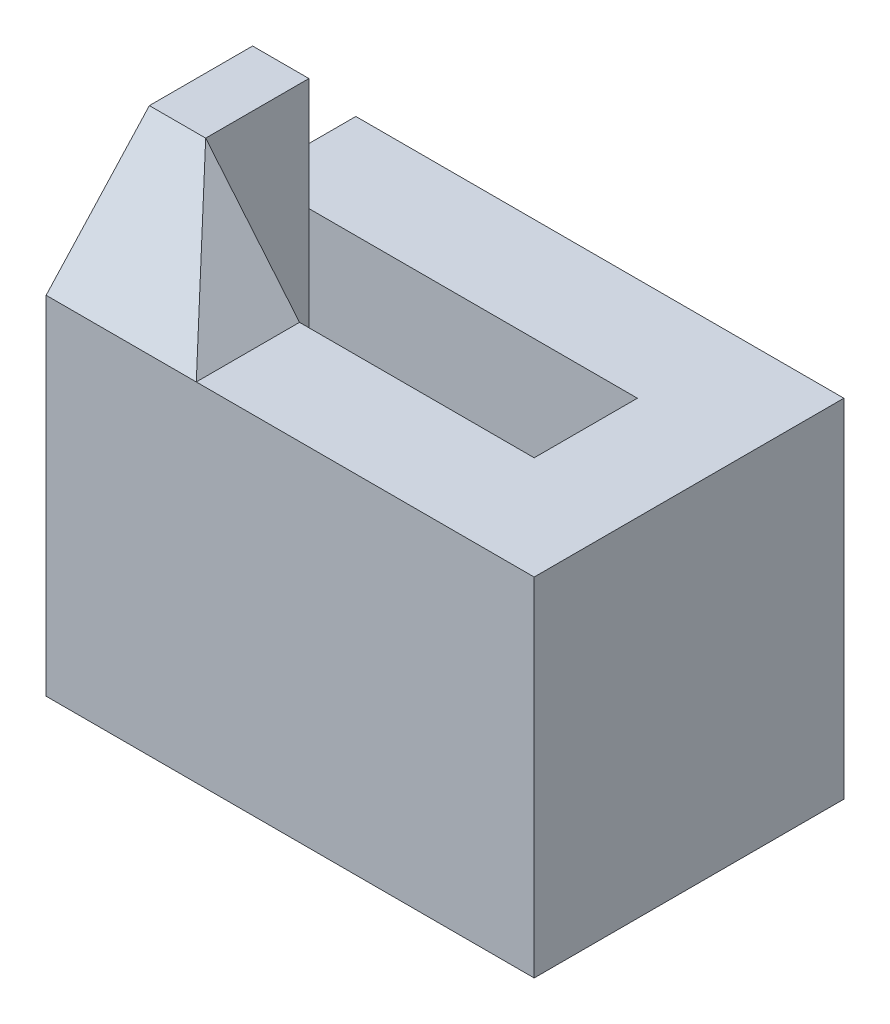
from build123d import *

# Parameters (mm, degrees)
SKETCH_1_W          = 52
SKETCH_1_H          = 33
SKETCH_1_W_2        = 22
SKETCH_1_H_2        = 11
EXTRUDE_1_DEPTH     = 37
SKETCH_3_W          = 13
SKETCH_3_H          = 11
CUT_EXTRUDE_1_DEPTH = 13
SKETCH_4_W          = 6
SKETCH_4_H          = 11
EXTRUDE_2_DEPTH     = 12
EXTRUDE_4_DEPTH     = 16
CUT_EXTRUDE_2_REACH = 35


with BuildPart() as part:
    # 草图1 → 凸台-拉伸1 (new body)
    with BuildSketch(Plane(origin=(0, 0, 0), x_dir=(1, 0, 0), z_dir=(0, 1, 0))):
        Rectangle(SKETCH_1_W, SKETCH_1_H)
        with Locations((-9, 0)):
            Rectangle(SKETCH_1_W_2, SKETCH_1_H_2, mode=Mode.SUBTRACT)
    extrude(amount=EXTRUDE_1_DEPTH)

    # 草图3 → 切除-拉伸1 (cut)
    with BuildSketch(Plane(origin=(0, 37, 0), x_dir=(1, 0, 0), z_dir=(0, 1, 0))):
        with Locations((8.5, 0)):
            Rectangle(SKETCH_3_W, SKETCH_3_H)
    extrude(amount=-CUT_EXTRUDE_1_DEPTH, mode=Mode.SUBTRACT)

    # 草图4 → 凸台-拉伸2 (add)
    with BuildSketch(Plane(origin=(0, 37, 0), x_dir=(1, 0, 0), z_dir=(0, 1, 0))):
        with Locations((-23, 0)):
            Rectangle(SKETCH_4_W, SKETCH_4_H)
    extrude(amount=EXTRUDE_2_DEPTH)

    # 草图6 → 凸台-拉伸4 (add)
    with BuildSketch(Plane.ZY.offset(26)):
        Polygon((5.5, 49), (16.5, 37), (5.5, 37), align=None)
    extrude(amount=-EXTRUDE_4_DEPTH)

    # 草图7 → 切除-拉伸2 (cut, up to next)
    with BuildSketch(Plane.XY.offset(16.5), mode=Mode.PRIVATE) as cut_extrude_2_sk1:
        Polygon((-20, 49), (-10, 37), (-10, 49), align=None)
    cut_extrude_2_tool1 = extrude(cut_extrude_2_sk1.sketch, amount=-CUT_EXTRUDE_2_REACH, mode=Mode.PRIVATE) & part.part
    add(cut_extrude_2_tool1.solids().sort_by_distance((-13.333333, 45, 16.5))[0], mode=Mode.SUBTRACT)


solid = part.part
